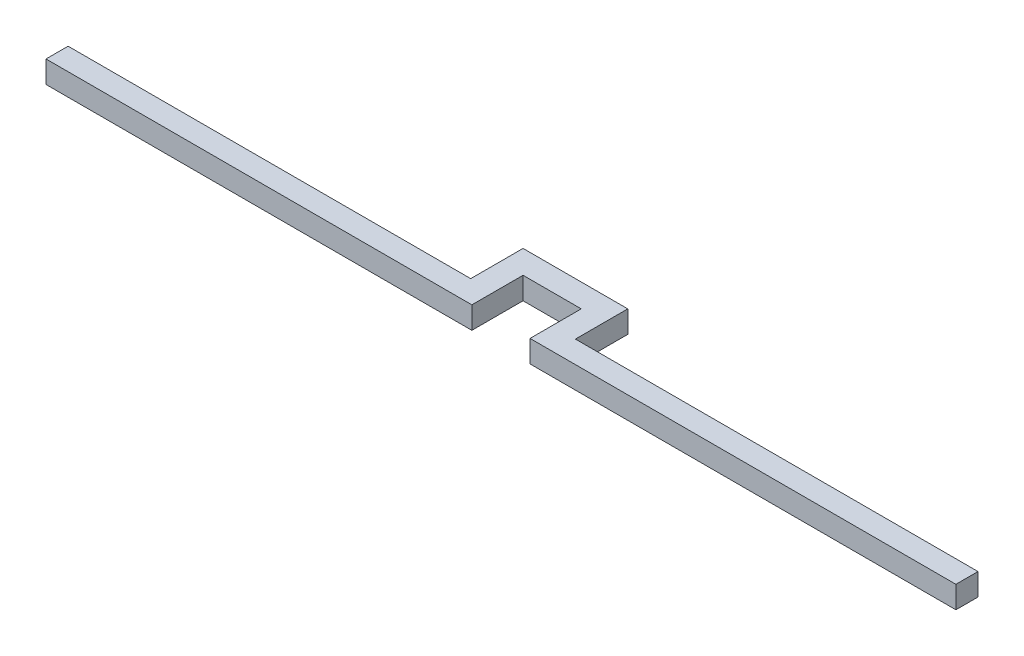
from build123d import *

# Parameters (mm, degrees)
BOSS_EXTRUDE1_DEPTH = 1.9


with BuildPart() as part:
    # Sketch1 → Boss-Extrude1 (new body)
    with BuildSketch(Plane(origin=(0, 0, 0), x_dir=(1, 0, 0), z_dir=(0, 1, 0))):
        Polygon((2.5, 3.5), (-2.5, 3.5), (-2.5, 1), (-2.5, -0.9), (-39.1, -0.9), (-39.1, 1), (-4.5, 1), (-4.5, 3.5), (-4.5, 5.5), (4.5, 5.5), (4.5, 3.5), (4.5, 1), (39.1, 1), (39.1, -0.9), (2.5, -0.9), (2.5, 1), align=None)
    extrude(amount=BOSS_EXTRUDE1_DEPTH)


solid = part.part
